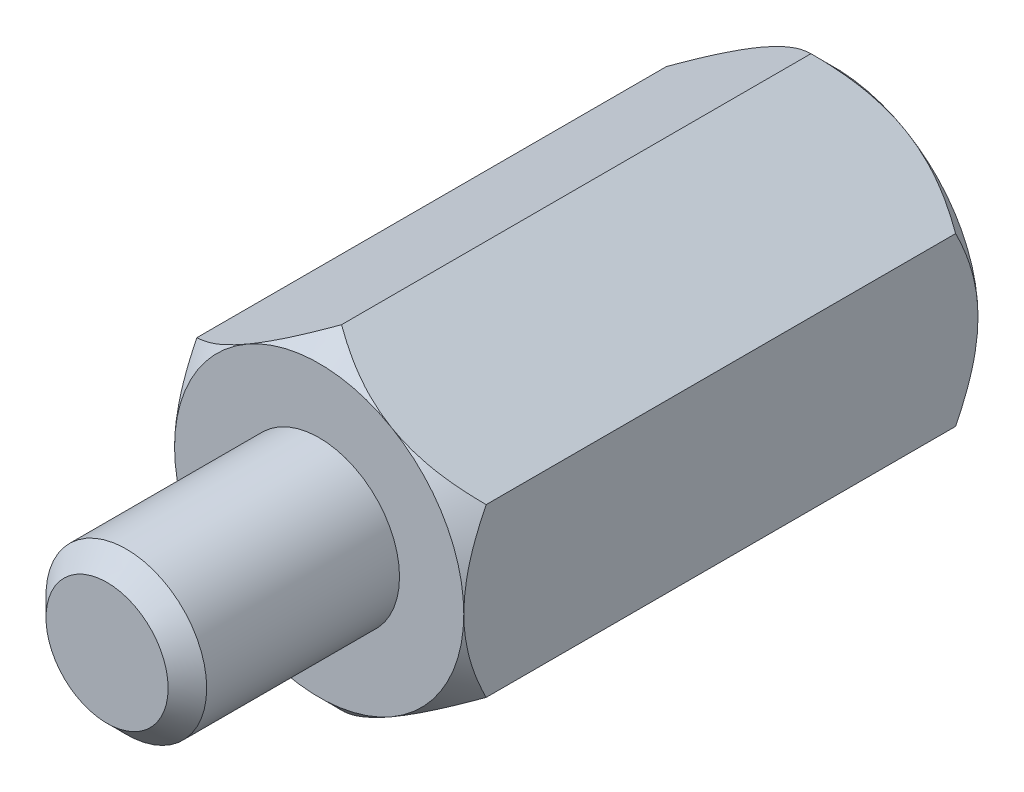
from build123d import *

# Parameters (mm, degrees)
SKETCH2_R           = 1.25
BOSS_EXTRUDE1_DEPTH = 3.3
BOSS_EXTRUDE2_DEPTH = 8
SKETCH4_R           = 1.25
CUT_EXTRUDE1_DEPTH  = 4.8
SKETCH5_OUTSIDE_W   = 33.746
SKETCH5_OUTSIDE_H   = 34.442
SKETCH5_OUTSIDE_R   = 2.25
CUT_EXTRUDE2_DEPTH  = 12.3
CUT_EXTRUDE2_TAPER  = 45
SKETCH6_OUTSIDE_W   = 27.146
SKETCH6_OUTSIDE_H   = 27.842
SKETCH6_OUTSIDE_R   = 2.25
CUT_EXTRUDE3_DEPTH  = 9
CUT_EXTRUDE3_TAPER  = 45
CHAMFER1_SIZE       = 0.3


with BuildPart() as part:
    # Sketch2 → Boss-Extrude1 (new body)
    with BuildSketch(Plane.XY):
        Circle(SKETCH2_R)
    extrude(amount=BOSS_EXTRUDE1_DEPTH)

    # Sketch3 → Boss-Extrude2 (add)
    with BuildSketch(Plane(origin=(0, 0, 0), x_dir=(-1, 0, 0), z_dir=(0, 0, -1))):
        Polygon((0, 2.598076211), (-2.25, 1.299038106), (-2.25, -1.299038106), (0, -2.598076211), (2.25, -1.299038106), (2.25, 1.299038106), align=None)
    extrude(amount=BOSS_EXTRUDE2_DEPTH)

    # Sketch4 → Cut-Extrude1 (cut)
    with BuildSketch(Plane(origin=(0, 0, -8), x_dir=(-1, 0, 0), z_dir=(0, 0, -1))):
        Circle(SKETCH4_R)
    extrude(amount=-CUT_EXTRUDE1_DEPTH, mode=Mode.SUBTRACT)

    # Sketch5 outside → Cut-Extrude2 (cut, through all)
    with BuildSketch(Plane(origin=(0, 0, -8), x_dir=(-1, 0, 0), z_dir=(0, 0, -1))):
        Rectangle(SKETCH5_OUTSIDE_W, SKETCH5_OUTSIDE_H)
        Circle(SKETCH5_OUTSIDE_R, mode=Mode.SUBTRACT)
    extrude(amount=-CUT_EXTRUDE2_DEPTH, taper=CUT_EXTRUDE2_TAPER, mode=Mode.SUBTRACT)

    # Sketch6 outside → Cut-Extrude3 (cut, through all)
    with BuildSketch(Plane.XY):
        Rectangle(SKETCH6_OUTSIDE_W, SKETCH6_OUTSIDE_H)
        Circle(SKETCH6_OUTSIDE_R, mode=Mode.SUBTRACT)
    extrude(amount=-CUT_EXTRUDE3_DEPTH, taper=CUT_EXTRUDE3_TAPER, mode=Mode.SUBTRACT)

    # Chamfer1
    chamfer1_edges = [part.edges().sort_by_distance(p)[0] for p in [
        (-1.25, 0, 3.3),
    ]]
    chamfer(chamfer1_edges, length=CHAMFER1_SIZE)


solid = part.part
